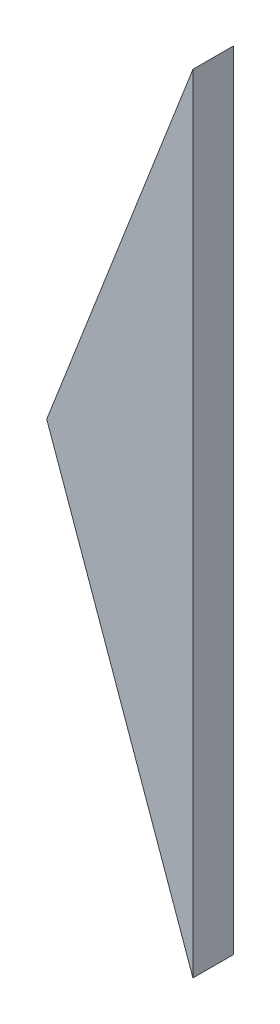
from build123d import *

# Parameters (mm, degrees)
BOSS_EXTRU_1_DEPTH = 3


with BuildPart() as part:
    # Esquisse1 → Boss.-Extru.1 (new body)
    with BuildSketch(Plane.XY):
        Polygon((-25.743066416, -66.222637248), (-14.873412892, -38.261045157), (-14.873412892, -96.769856796), align=None)
    extrude(amount=-BOSS_EXTRU_1_DEPTH)


solid = part.part
